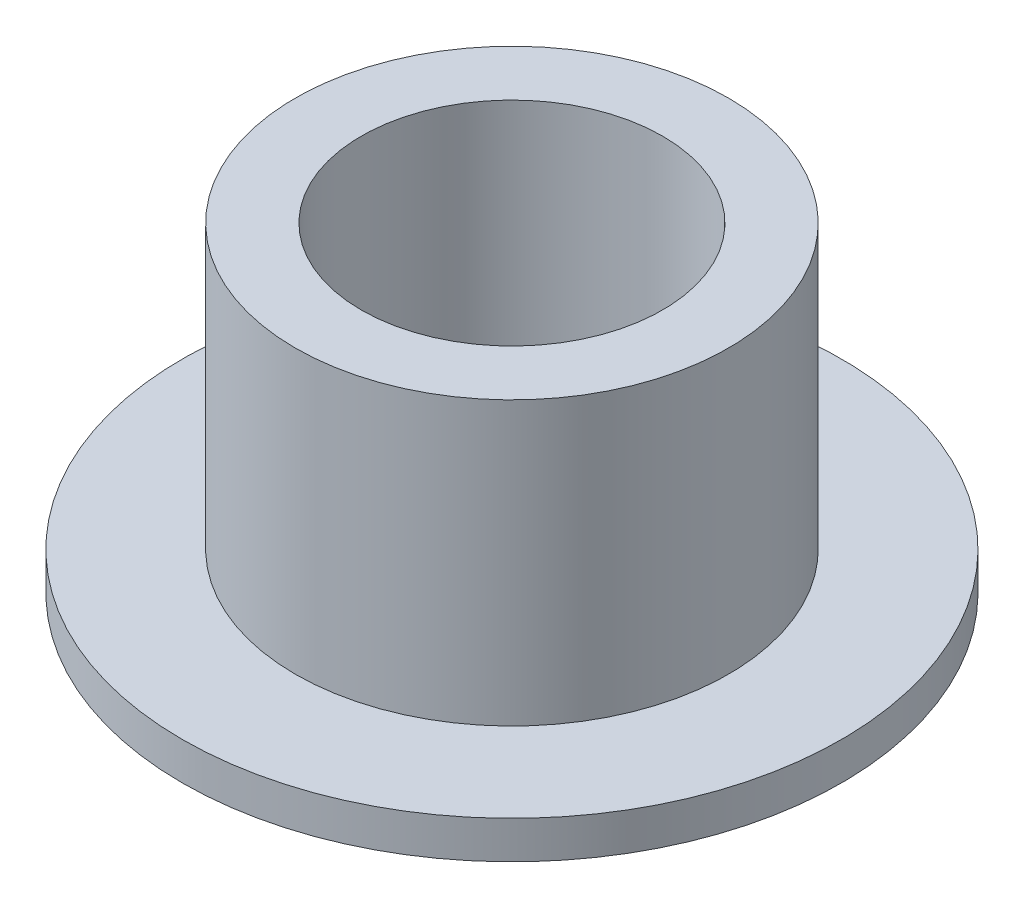
from build123d import *

# Parameters (mm, degrees)
SKETCH1_R           = 3.5
BOSS_EXTRUDE1_DEPTH = 0.4
SKETCH2_R           = 2.3
BOSS_EXTRUDE2_DEPTH = 3
SKETCH3_R           = 1.6
CUT_EXTRUDE1_DEPTH  = 16


with BuildPart() as part:
    # Sketch1 → Boss-Extrude1 (new body)
    with BuildSketch(Plane(origin=(0, 0, 0), x_dir=(1, 0, 0), z_dir=(0, 1, 0))):
        Circle(SKETCH1_R)
    extrude(amount=BOSS_EXTRUDE1_DEPTH)

    # Sketch2 → Boss-Extrude2 (add)
    with BuildSketch(Plane(origin=(0, 0.4, 0), x_dir=(1, 0, 0), z_dir=(0, 1, 0))):
        Circle(SKETCH2_R)
    extrude(amount=BOSS_EXTRUDE2_DEPTH)

    # Sketch3 → Cut-Extrude1 (cut)
    with BuildSketch(Plane(origin=(0, 3.4, 0), x_dir=(1, 0, 0), z_dir=(0, 1, 0))):
        Circle(SKETCH3_R)
    extrude(amount=-CUT_EXTRUDE1_DEPTH, mode=Mode.SUBTRACT)


solid = part.part
